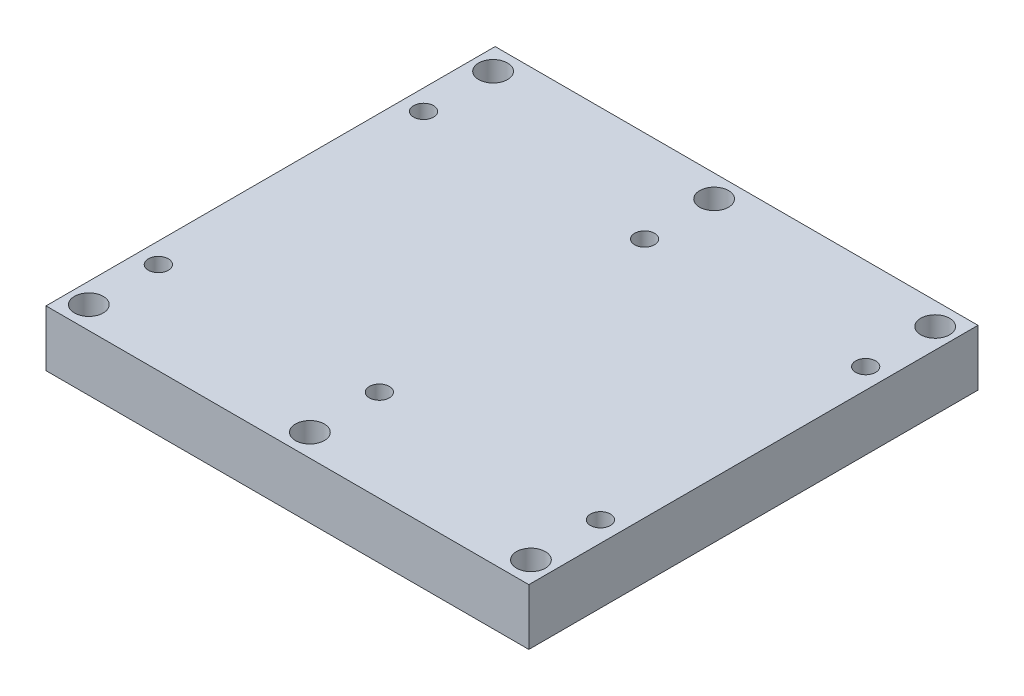
from build123d import *

# Parameters (mm, degrees)
SKETCH1_W                 = 54.61
SKETCH1_H                 = 50.8
BOSS_EXTRUDE1_DEPTH       = 6.35
F_4_40_TAPPED_HOLE1_D     = 2.2606
F_4_40_TAPPED_HOLE1_DEPTH = 6.35
F_4_CLEARANCE_HOLE1_D     = 3.2639
F_4_CLEARANCE_HOLE1_DEPTH = 6.35


with BuildPart() as part:
    # Sketch1 → Boss-Extrude1 (new body)
    with BuildSketch(Plane(origin=(0, 0, 0), x_dir=(1, 0, 0), z_dir=(0, 1, 0))):
        Rectangle(SKETCH1_W, SKETCH1_H)
    extrude(amount=BOSS_EXTRUDE1_DEPTH)

    # #4-40 Tapped Hole1
    with Locations(Plane(origin=(0, 6.35, 0), x_dir=(1, 0, 0), z_dir=(0, 1, 0))):
        with Locations((-25, 15), (8e-07, 15), (25.0000016, 15), (8e-07, -14.9999908), (25.0000016, -14.9999908), (-25, -14.9999908)):
            Hole(F_4_40_TAPPED_HOLE1_D / 2, depth=F_4_40_TAPPED_HOLE1_DEPTH)

    # #4 Clearance Hole1
    with Locations(Plane(origin=(0, 6.35, 0), x_dir=(1, 0, 0), z_dir=(0, 1, 0))):
        with Locations((-25, 22.86), (0, 22.86), (25, 22.86), (0, -22.86), (25, -22.86), (-25, -22.86)):
            Hole(F_4_CLEARANCE_HOLE1_D / 2, depth=F_4_CLEARANCE_HOLE1_DEPTH)


solid = part.part
